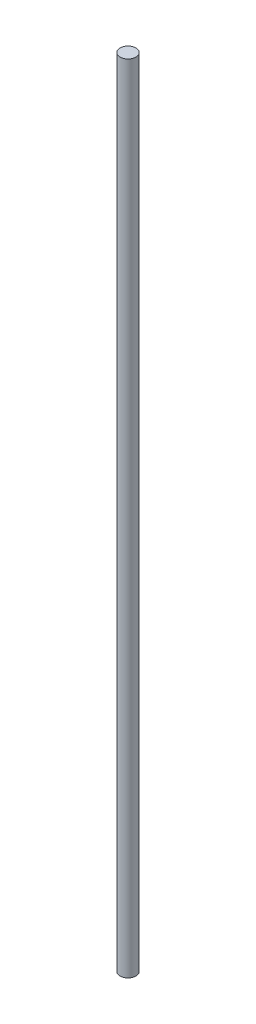
from build123d import *

# Parameters (mm, degrees)
SKETCH1_R           = 2
BOSS_EXTRUDE1_DEPTH = 200


with BuildPart() as part:
    # Sketch1 → Boss-Extrude1 (new body)
    with BuildSketch(Plane(origin=(0, 0, 0), x_dir=(1, 0, 0), z_dir=(0, 1, 0))):
        Circle(SKETCH1_R)
    extrude(amount=BOSS_EXTRUDE1_DEPTH)


solid = part.part
